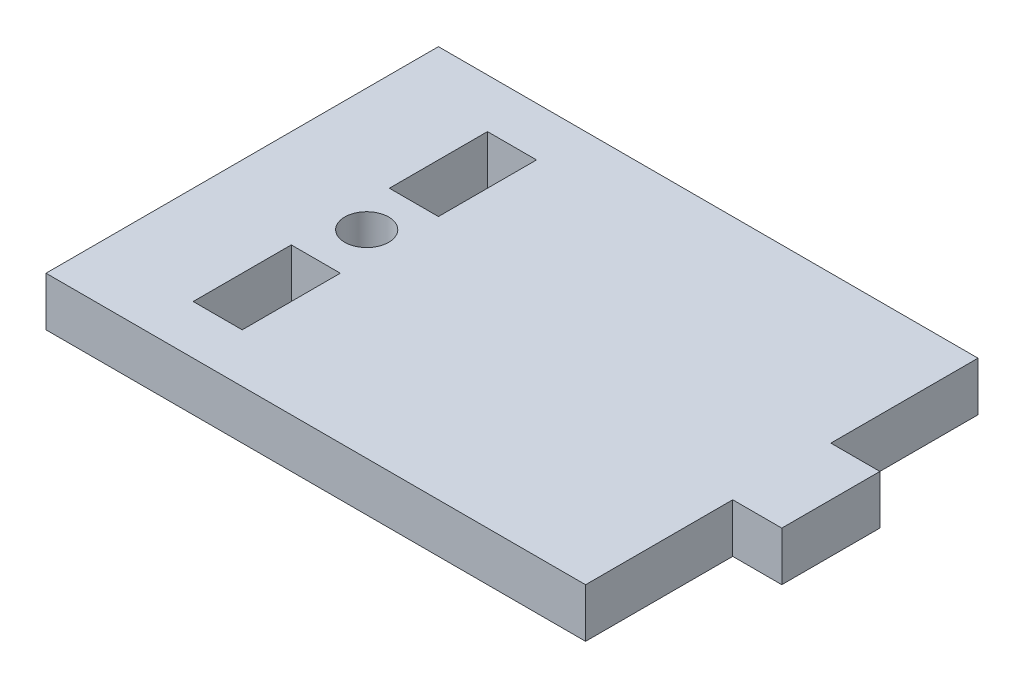
from build123d import *

# Parameters (mm, degrees)
SKETCH1_R           = 2.846646533
SKETCH1_W           = 6.35
SKETCH1_H           = 12.7
BOSS_EXTRUDE1_DEPTH = 6.35


with BuildPart() as part:
    # Sketch1 → Boss-Extrude1 (new body)
    with BuildSketch(Plane(origin=(0, 0, 0), x_dir=(1, 0, 0), z_dir=(0, 1, 0))):
        Polygon((0, 0), (69.85, 0), (69.85, 19.05), (76.2, 19.05), (76.2, 31.75), (69.85, 31.75), (69.85, 50.8), (0, 50.8), align=None)
        with Locations((15.875, 25.640429005)):
            Circle(SKETCH1_R, mode=Mode.SUBTRACT)
        with Locations((15.875, 38.1)):
            Rectangle(SKETCH1_W, SKETCH1_H, mode=Mode.SUBTRACT)
        with Locations((15.875, 12.7)):
            Rectangle(SKETCH1_W, SKETCH1_H, mode=Mode.SUBTRACT)
    extrude(amount=BOSS_EXTRUDE1_DEPTH)


solid = part.part
